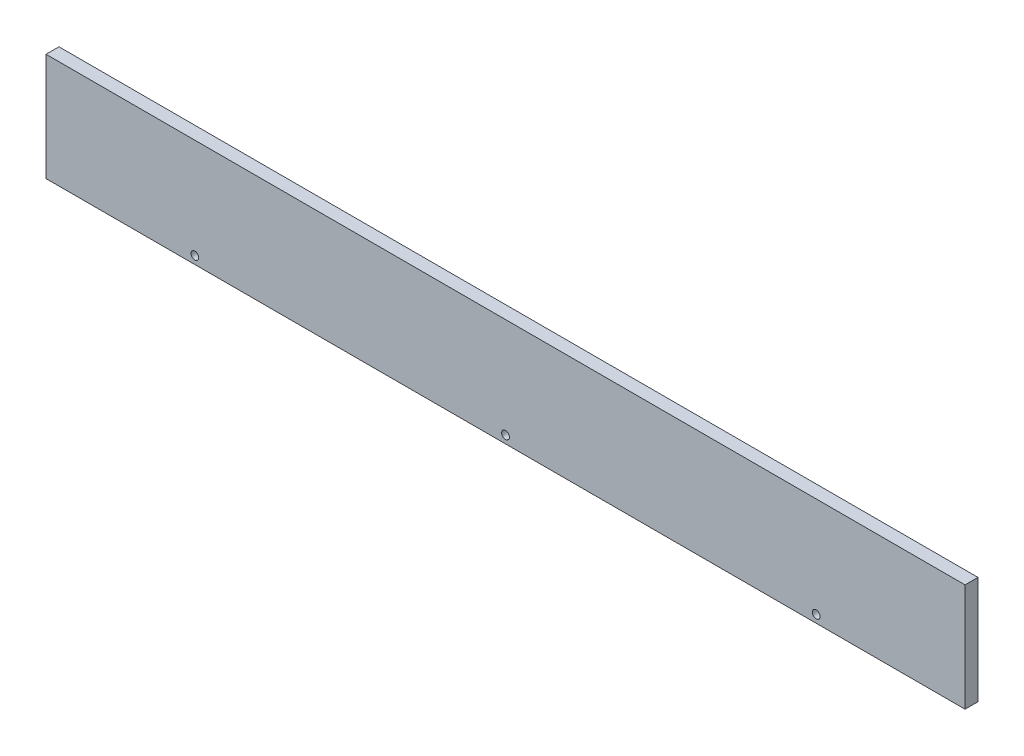
from build123d import *

# Parameters (mm, degrees)
SKETCH1_W           = 450.85
SKETCH1_H           = 52.832
BOSS_EXTRUDE1_DEPTH = 6.35
SKETCH2_R           = 1.905
CUT_EXTRUDE1_DEPTH  = 6.35


with BuildPart() as part:
    # Sketch1 → Boss-Extrude1 (new body)
    with BuildSketch(Plane.XY):
        with Locations((225.425, -26.416)):
            Rectangle(SKETCH1_W, SKETCH1_H)
    extrude(amount=BOSS_EXTRUDE1_DEPTH)

    # Sketch2 → Cut-Extrude1 (cut)
    with BuildSketch(Plane.XY.offset(6.35)):
        with Locations((73.025, -49.022)):
            Circle(SKETCH2_R)
        with Locations((225.425, -49.022)):
            Circle(SKETCH2_R)
        with Locations((377.825, -49.022)):
            Circle(SKETCH2_R)
    extrude(amount=-CUT_EXTRUDE1_DEPTH, mode=Mode.SUBTRACT)


solid = part.part
